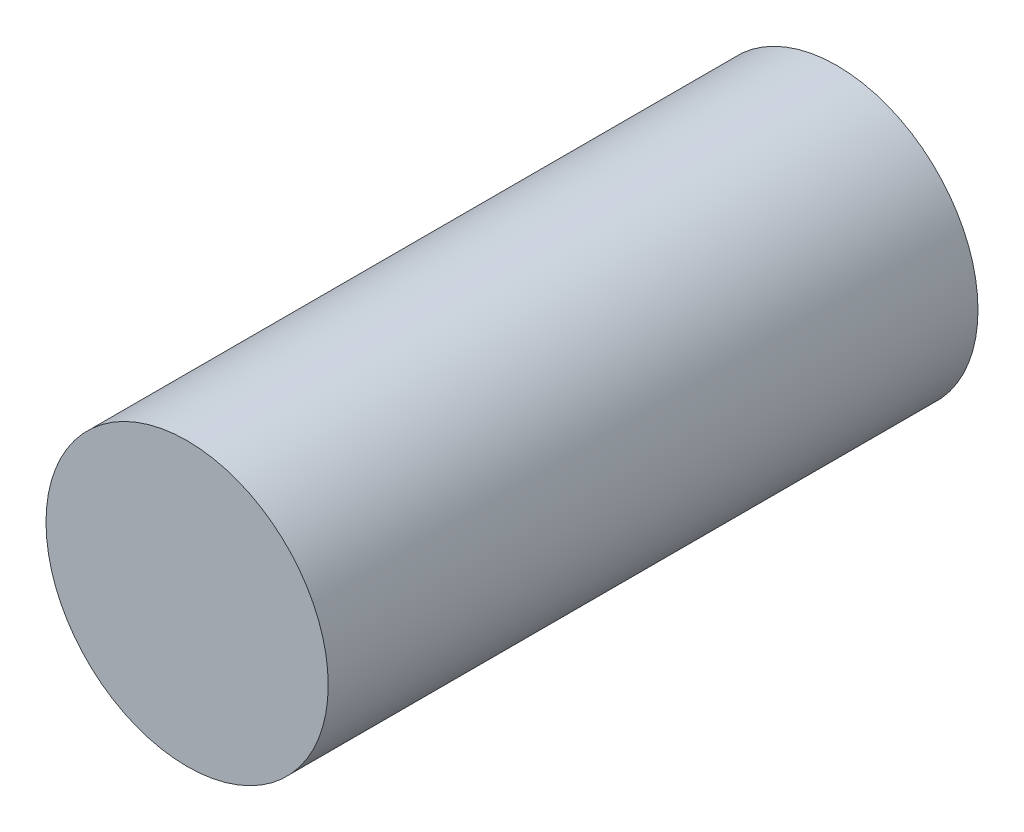
from build123d import *

# Parameters (mm, degrees)
CROQUIS1_R              = 15.2
SALIENTE_EXTRUIR1_DEPTH = 70


with BuildPart() as part:
    # Croquis1 → Saliente-Extruir1 (new body)
    with BuildSketch(Plane.XY):
        Circle(CROQUIS1_R)
    extrude(amount=SALIENTE_EXTRUIR1_DEPTH)


solid = part.part
